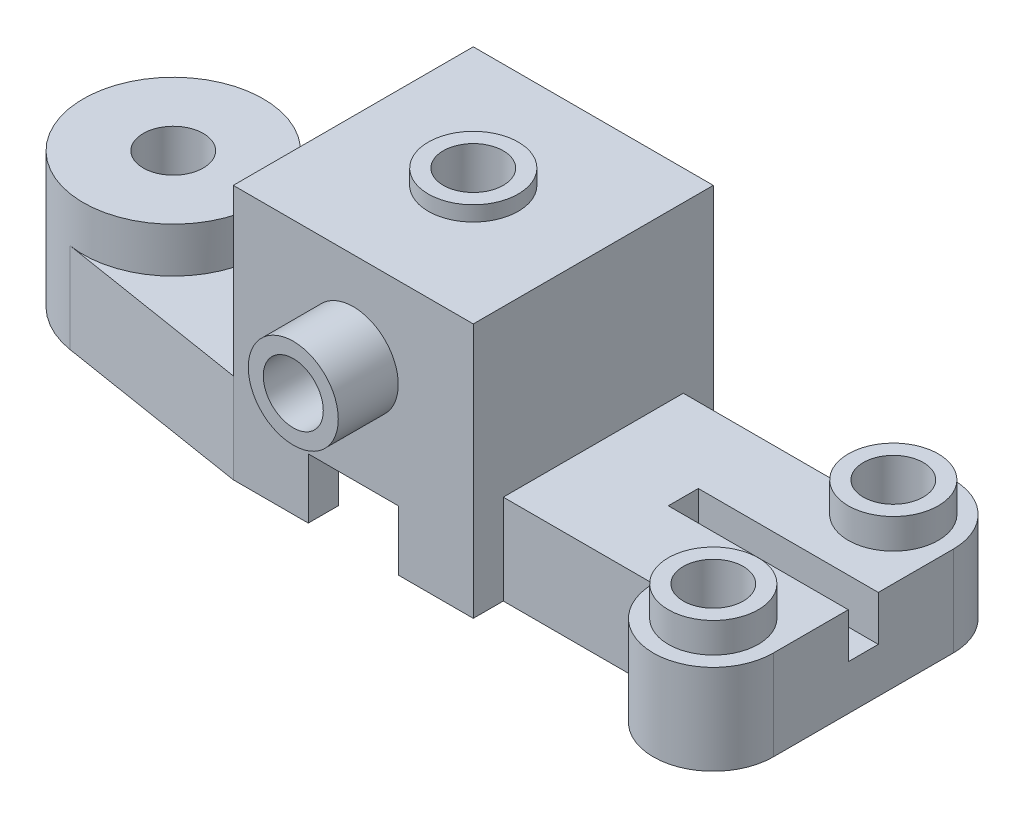
from build123d import *

# Parameters (mm, degrees)
BOSS_EXTRUDE2_DEPTH = 30
SKETCH2_W           = 80
SKETCH2_H           = 80
BOSS_EXTRUDE3_DEPTH = 55
CUT_EXTRUDE1_DEPTH  = 70
SKETCH4_R           = 15
BOSS_EXTRUDE4_DEPTH = 5
SKETCH6_R           = 10
CUT_EXTRUDE2_DEPTH  = 91
SKETCH7_R           = 30
BOSS_EXTRUDE5_DEPTH = 15
SKETCH8_R           = 10
CUT_EXTRUDE3_DEPTH  = 46
CUT_EXTRUDE4_DEPTH  = 15
SKETCH11_W          = 30
SKETCH11_H          = 20
CUT_EXTRUDE5_DEPTH  = 91
SKETCH12_R          = 15
BOSS_EXTRUDE6_DEPTH = 20
CUT_EXTRUDE6_REACH  = 112
SKETCH13_R          = 10
SKETCH14_R          = 15
BOSS_EXTRUDE7_DEPTH = 10
SKETCH15_R          = 10
CUT_EXTRUDE7_DEPTH  = 15
SKETCH16_R          = 5
CUT_EXTRUDE8_DEPTH  = 26
SKETCH17_W          = 60
SKETCH17_H          = 10
CUT_EXTRUDE9_DEPTH  = 15
RIB1_REACH          = 62
SKETCH18_WALL_W     = 172
SKETCH18_WALL_H     = 10


with BuildPart() as part:
    # Sketch1 → Boss-Extrude2 (new body)
    with BuildSketch(Plane(origin=(0, 0, 0), x_dir=(1, 0, 0), z_dir=(0, 1, 0))):
        with BuildLine():
            Line((130, 30), (130, -30))
            ThreePointArc((130, -30), (110, -50), (90, -30))
            Line((90, -30), (40, -30))
            Line((40, -30), (40, -40))
            Line((40, -40), (-40, -40))
            Line((-40, -40), (-104.747935056, -29.621902584))
            ThreePointArc((-104.747935056, -29.621902584), (-130, 0), (-104.747935056, 29.621902584))
            Line((-104.747935056, 29.621902584), (-40, 40))
            Line((-40, 40), (40, 40))
            Line((40, 40), (40, 30))
            Line((40, 30), (90, 30))
            ThreePointArc((90, 30), (110, 50), (130, 30))
        make_face()
    extrude(amount=BOSS_EXTRUDE2_DEPTH)

    # Sketch2 → Boss-Extrude3 (add)
    with BuildSketch(Plane(origin=(0, 30, 0), x_dir=(1, 0, 0), z_dir=(0, 1, 0))):
        Rectangle(SKETCH2_W, SKETCH2_H)
    extrude(amount=BOSS_EXTRUDE3_DEPTH)

    # Sketch3 → Cut-Extrude1 (cut)
    with BuildSketch(Plane.XZ):
        with BuildLine():
            Line((-20, -30), (20, -30))
            ThreePointArc((20, -30), (27.071067812, -27.071067812), (30, -20))
            Line((30, -20), (30, 20))
            ThreePointArc((30, 20), (27.071067812, 27.071067812), (20, 30))
            Line((20, 30), (-20, 30))
            ThreePointArc((-20, 30), (-27.071067812, 27.071067812), (-30, 20))
            Line((-30, 20), (-30, -20))
            ThreePointArc((-30, -20), (-27.071067812, -27.071067812), (-20, -30))
        make_face()
    extrude(amount=-CUT_EXTRUDE1_DEPTH, mode=Mode.SUBTRACT)

    # Sketch4 → Boss-Extrude4 (add)
    with BuildSketch(Plane(origin=(0, 85, 0), x_dir=(1, 0, 0), z_dir=(0, 1, 0))):
        with Locations(Location((0, 0, 0), (0, 0, 270))):  # turned: the seam where the file's is
            Circle(SKETCH4_R)
    extrude(amount=BOSS_EXTRUDE4_DEPTH)

    # Sketch6 → Cut-Extrude2 (cut, through all)
    with BuildSketch(Plane(origin=(0, 90, 0), x_dir=(1, 0, 0), z_dir=(0, 1, 0))):
        with Locations(Location((0, 0, 0), (0, 0, 270))):  # turned: the seam where the file's is
            Circle(SKETCH6_R)
    extrude(amount=-CUT_EXTRUDE2_DEPTH, mode=Mode.SUBTRACT)

    # Sketch7 → Boss-Extrude5 (add)
    with BuildSketch(Plane(origin=(0, 30, 0), x_dir=(1, 0, 0), z_dir=(0, 1, 0))):
        with Locations(Location((-100, 0, 0), (0, 0, 99.10617604))):  # turned: the seam where the file's is
            Circle(SKETCH7_R)
    extrude(amount=BOSS_EXTRUDE5_DEPTH)

    # Sketch8 → Cut-Extrude3 (cut, through all)
    with BuildSketch(Plane(origin=(0, 45, 0), x_dir=(1, 0, 0), z_dir=(0, 1, 0))):
        with Locations(Location((-100, 0, 0), (0, 0, 270))):  # turned: the seam where the file's is
            Circle(SKETCH8_R)
    extrude(amount=-CUT_EXTRUDE3_DEPTH, mode=Mode.SUBTRACT)

    # Sketch9 → Cut-Extrude4 (cut)
    with BuildSketch(Plane.XZ):
        with BuildLine():
            Line((-50, 28.269512751), (-50, -28.269512751))
            Line((-50, -28.269512751), (-103.165290037, -19.747935056))
            ThreePointArc((-103.165290037, -19.747935056), (-120, 0), (-103.165290037, 19.747935056))
            Line((-103.165290037, 19.747935056), (-50, 28.269512751))
        make_face()
    extrude(amount=-CUT_EXTRUDE4_DEPTH, mode=Mode.SUBTRACT)

    # Sketch11 → Cut-Extrude5 (cut, through all)
    with BuildSketch(Plane.XY.offset(40)):
        with Locations((0, 10)):
            Rectangle(SKETCH11_W, SKETCH11_H)
    extrude(amount=-CUT_EXTRUDE5_DEPTH, mode=Mode.SUBTRACT)

    # Sketch12 → Boss-Extrude6 (add)
    with BuildSketch(Plane.XY.offset(40)):
        with Locations(Location((0, 55, 0), (0, 0, 180))):  # turned: the seam where the file's is
            Circle(SKETCH12_R)
    extrude(amount=BOSS_EXTRUDE6_DEPTH)

    # Sketch13 → Cut-Extrude6 (cut, up to next)
    with BuildSketch(Plane.XY.offset(60), mode=Mode.PRIVATE) as cut_extrude6_sk1:
        with Locations((0, 55)):
            Circle(SKETCH13_R)
    cut_extrude6_tool1 = extrude(cut_extrude6_sk1.sketch, amount=-CUT_EXTRUDE6_REACH, mode=Mode.PRIVATE) & part.part
    add(cut_extrude6_tool1.solids().sort_by_distance((0, 55, 60))[0], mode=Mode.SUBTRACT)

    # Sketch14 → Boss-Extrude7 (add)
    with BuildSketch(Plane(origin=(0, 30, 0), x_dir=(1, 0, 0), z_dir=(0, 1, 0))):
        with Locations(Location((110, -30, 0), (0, 0, 270))):  # turned: the seam where the file's is
            Circle(SKETCH14_R)
        with Locations(Location((110, 30, 0), (0, 0, 270))):  # turned: the seam where the file's is
            Circle(SKETCH14_R)
    extrude(amount=BOSS_EXTRUDE7_DEPTH)

    # Sketch15 → Cut-Extrude7 (cut)
    with BuildSketch(Plane(origin=(0, 40, 0), x_dir=(1, 0, 0), z_dir=(0, 1, 0))):
        with Locations(Location((110, -30, 0), (0, 0, 270))):  # turned: the seam where the file's is
            Circle(SKETCH15_R)
        with Locations(Location((110, 30, 0), (0, 0, 270))):  # turned: the seam where the file's is
            Circle(SKETCH15_R)
    extrude(amount=-CUT_EXTRUDE7_DEPTH, mode=Mode.SUBTRACT)

    # Sketch16 → Cut-Extrude8 (cut, through all)
    with BuildSketch(Plane(origin=(0, 25, 0), x_dir=(1, 0, 0), z_dir=(0, 1, 0))):
        with Locations(Location((110, -30, 0), (0, 0, 270))):  # turned: the seam where the file's is
            Circle(SKETCH16_R)
        with Locations(Location((110, 30, 0), (0, 0, 270))):  # turned: the seam where the file's is
            Circle(SKETCH16_R)
    extrude(amount=-CUT_EXTRUDE8_DEPTH, mode=Mode.SUBTRACT)

    # Sketch17 → Cut-Extrude9 (cut)
    with BuildSketch(Plane(origin=(0, 30, 0), x_dir=(1, 0, 0), z_dir=(0, 1, 0))):
        with Locations((100, 0)):
            Rectangle(SKETCH17_W, SKETCH17_H)
    extrude(amount=-CUT_EXTRUDE9_DEPTH, mode=Mode.SUBTRACT)

    # Sketch18 wall → Rib1 (add, up to next)
    with BuildSketch(Plane(origin=(-55, 65, 0), x_dir=(0.6, 0.8, 0), z_dir=(-0.8, 0.6, 0)), mode=Mode.PRIVATE) as rib1_sk1:
        Rectangle(SKETCH18_WALL_W, SKETCH18_WALL_H)
    rib1_tool1 = extrude(rib1_sk1.sketch, amount=-RIB1_REACH, mode=Mode.PRIVATE) - part.part
    add(rib1_tool1.solids().sort_by_distance((-55, 65, 0))[0])


solid = part.part
